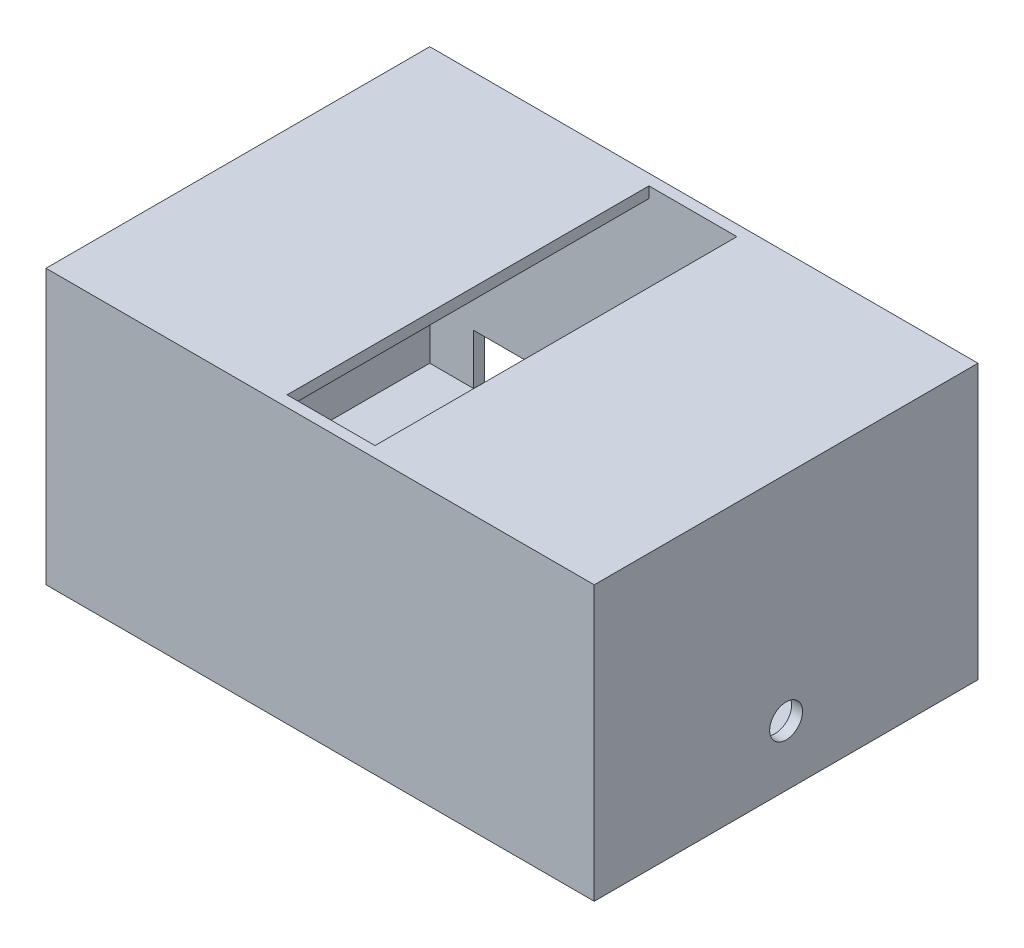
from build123d import *

# Parameters (mm, degrees)
SKETCH1_W           = 250
SKETCH1_H           = 175
BOSS_EXTRUDE1_DEPTH = 125
SKETCH2_W           = 240
SKETCH2_H           = 165
CUT_EXTRUDE1_DEPTH  = 120
SKETCH3_W           = 40.1
SKETCH3_H           = 165
CUT_EXTRUDE2_DEPTH  = 126
SKETCH4_R           = 7.5
CUT_EXTRUDE3_DEPTH  = 251
SKETCH6_W           = 250
SKETCH6_H           = 175
BOSS_EXTRUDE2_DEPTH = 5
SKETCH7_W           = 200
SKETCH7_H           = 23
CUT_EXTRUDE4_DEPTH  = 5


with BuildPart() as part:
    # Sketch1 → Boss-Extrude1 (new body)
    with BuildSketch(Plane(origin=(0, 0, 0), x_dir=(1, 0, 0), z_dir=(0, 1, 0))):
        Rectangle(SKETCH1_W, SKETCH1_H)
    extrude(amount=-BOSS_EXTRUDE1_DEPTH)

    # Sketch2 → Cut-Extrude1 (cut)
    with BuildSketch(Plane.XZ.offset(125)):
        Rectangle(SKETCH2_W, SKETCH2_H)
    extrude(amount=-CUT_EXTRUDE1_DEPTH, mode=Mode.SUBTRACT)

    # Sketch3 → Cut-Extrude2 (cut, through all)
    with BuildSketch(Plane(origin=(0, 0, 0), x_dir=(1, 0, 0), z_dir=(0, 1, 0))):
        Rectangle(SKETCH3_W, SKETCH3_H)
    extrude(amount=-CUT_EXTRUDE2_DEPTH, mode=Mode.SUBTRACT)

    # Sketch4 → Cut-Extrude3 (cut, through all)
    with BuildSketch(Plane.ZY.offset(125)):
        with Locations((0, -97.5)):
            Circle(SKETCH4_R)
    extrude(amount=-CUT_EXTRUDE3_DEPTH, mode=Mode.SUBTRACT)

    # Sketch6 → Boss-Extrude2 (add)
    with BuildSketch(Plane.XZ.offset(125)):
        Rectangle(SKETCH6_W, SKETCH6_H)
    extrude(amount=-BOSS_EXTRUDE2_DEPTH)

    # Sketch7 → Cut-Extrude4 (cut)
    with BuildSketch(Plane(origin=(0, 0, -87.5), x_dir=(-1, 0, 0), z_dir=(0, 0, -1))):
        with Locations((0, -108.5)):
            Rectangle(SKETCH7_W, SKETCH7_H)
    extrude(amount=-CUT_EXTRUDE4_DEPTH, mode=Mode.SUBTRACT)


solid = part.part
